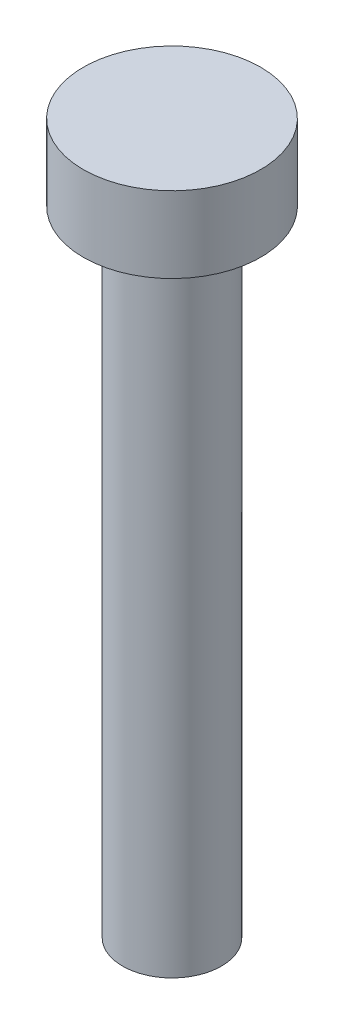
from build123d import *

# Parameters (mm, degrees)
SKETCH1_R           = 3.5
BOSS_EXTRUDE1_DEPTH = 3
SKETCH2_R           = 1.95
BOSS_EXTRUDE2_DEPTH = 25


with BuildPart() as part:
    # Sketch1 → Boss-Extrude1 (new body)
    with BuildSketch(Plane(origin=(0, 0, 0), x_dir=(1, 0, 0), z_dir=(0, 1, 0))):
        Circle(SKETCH1_R)
    extrude(amount=BOSS_EXTRUDE1_DEPTH)

    # Sketch2 → Boss-Extrude2 (add)
    with BuildSketch(Plane.XZ):
        Circle(SKETCH2_R)
    extrude(amount=BOSS_EXTRUDE2_DEPTH)


solid = part.part
